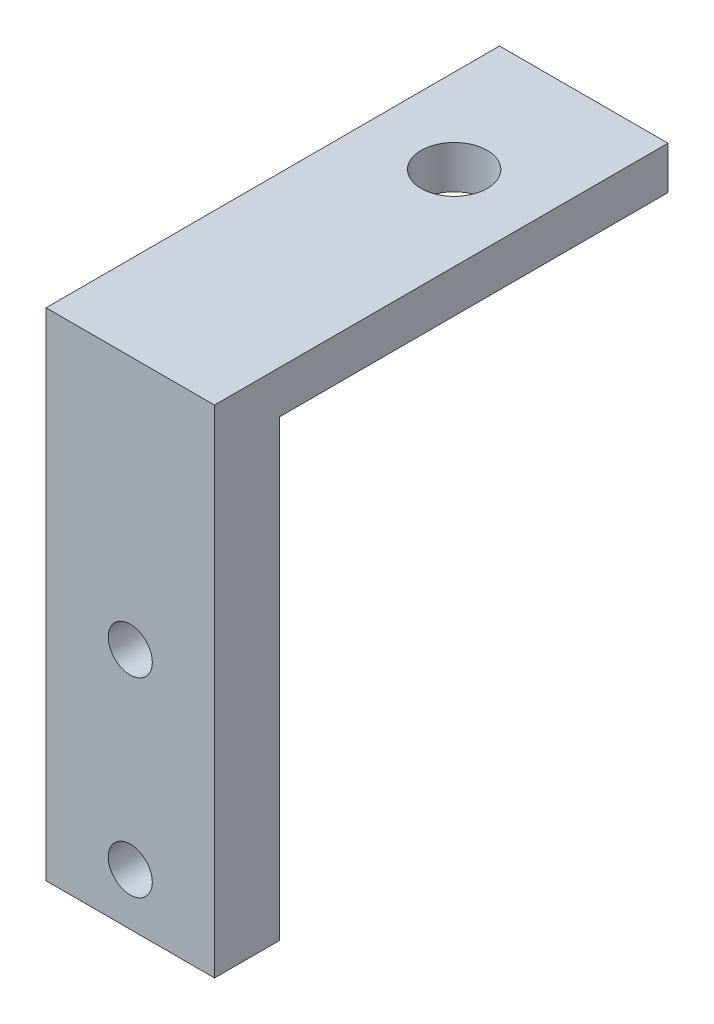
from build123d import *

# Parameters (mm, degrees)
BOSS_EXTRUDE1_DEPTH = 13
SKETCH2_R           = 1.7
CUT_EXTRUDE1_DEPTH  = 6
SKETCH3_R           = 2.55
CUT_EXTRUDE2_DEPTH  = 39.3


with BuildPart() as part:
    # Sketch1 → Boss-Extrude1 (new body)
    with BuildSketch(Plane(origin=(0, 0, 0), x_dir=(0, 0, -1), z_dir=(1, 0, 0))):
        Polygon((0, 0), (0, 38.3), (35, 38.3), (35, 35), (5, 35), (5, 0), align=None)
    extrude(amount=BOSS_EXTRUDE1_DEPTH)

    # Sketch2 → Cut-Extrude1 (cut, through all)
    with BuildSketch(Plane(origin=(0, 0, -5), x_dir=(-1, 0, 0), z_dir=(0, 0, -1))):
        with Locations((-6.5, 18.7)):
            Circle(SKETCH2_R)
        with Locations((-6.5, 4)):
            Circle(SKETCH2_R)
    extrude(amount=-CUT_EXTRUDE1_DEPTH, mode=Mode.SUBTRACT)

    # Sketch3 → Cut-Extrude2 (cut, through all)
    with BuildSketch(Plane(origin=(0, 38.3, 0), x_dir=(1, 0, 0), z_dir=(0, 1, 0))):
        with Locations((6.5, 25)):
            Circle(SKETCH3_R)
    extrude(amount=-CUT_EXTRUDE2_DEPTH, mode=Mode.SUBTRACT)


solid = part.part
